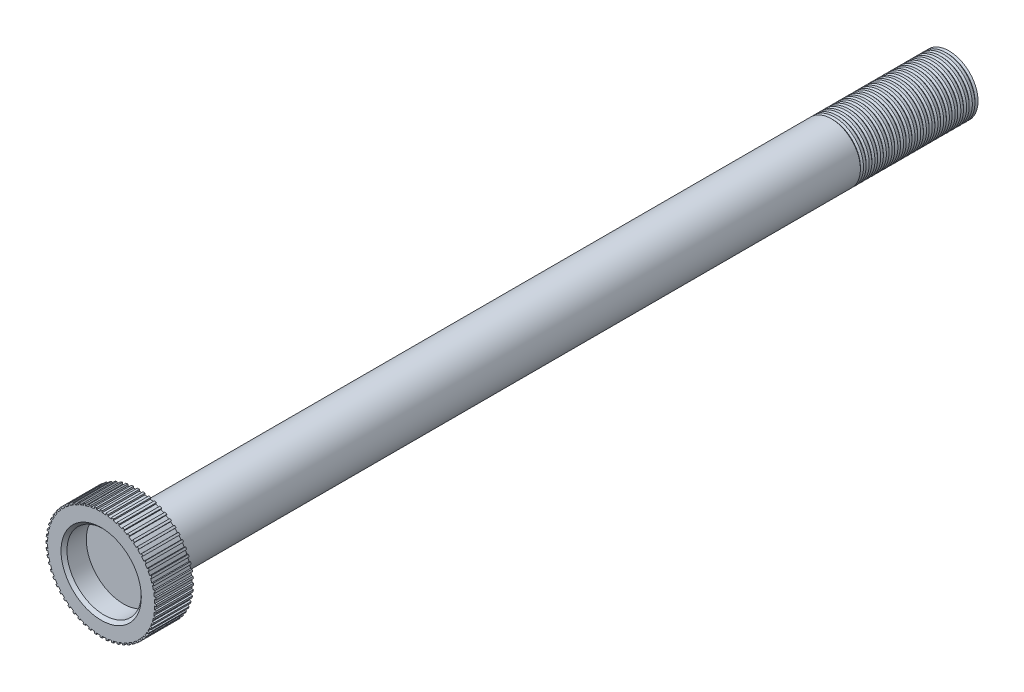
from build123d import *

# Parameters (mm, degrees)
SKETCH1_R          = 9.144
EXTRUDE1_DEPTH     = 6.35
SKETCH2_R          = 6.35
CUT_EXTRUDE1_DEPTH = 3.81
CHAMFER1_SIZE      = 0.508
SKETCH3_R          = 4.953
EXTRUDE2_DEPTH     = 138.43
SKETCH4_W          = 0.35026322
SKETCH4_H          = 0.444823542
EXTRUDE3_DEPTH     = 6.35
CIRPATTERN1_COUNT  = 60
LPATTERN1_COUNT    = 21
LPATTERN1_PITCH    = 0.978000076


with BuildPart() as part:
    # Sketch1 → Extrude1 (new body)
    with BuildSketch(Plane.XY):
        Circle(SKETCH1_R)
    extrude(amount=EXTRUDE1_DEPTH)

    # Sketch2 → Cut-Extrude1 (cut)
    with BuildSketch(Plane.XY.offset(6.35)):
        Circle(SKETCH2_R)
    extrude(amount=-CUT_EXTRUDE1_DEPTH, mode=Mode.SUBTRACT)

    # Chamfer1
    chamfer1_edges = [part.edges().sort_by_distance(p)[0] for p in [
        (-6.35, 0, 6.35),
    ]]
    chamfer(chamfer1_edges, length=CHAMFER1_SIZE)

    # Sketch3 → Extrude2 (add)
    with BuildSketch(Plane(origin=(0, 0, 0), x_dir=(-1, 0, 0), z_dir=(0, 0, -1))):
        Circle(SKETCH3_R)
    extrude(amount=EXTRUDE2_DEPTH)

    # Sketch4 → Extrude3 (add)
    with BuildSketch(Plane.XY):
        with Locations((0, 9.197906763)):
            Rectangle(SKETCH4_W, SKETCH4_H)
    extrude3 = extrude(amount=EXTRUDE3_DEPTH)

    # CirPattern1: Extrude3 ×60 about axis
    cirpattern1_axis = Axis((0, 0, 0), (0, 0, 1))
    for i in range(1, CIRPATTERN1_COUNT):
        add(extrude3.rotate(cirpattern1_axis, i * 360 / CIRPATTERN1_COUNT))

    # Sketch5 → Cut-Revolve1 (revolve, cut)
    with BuildSketch(Plane(origin=(0, 0, 0), x_dir=(1, 0, 0), z_dir=(0, 1, 0))):
        Polygon((-4.953, 138.43), (-4.687658819, 138.164658819), (-4.953, 137.899317638), (-5.218341181, 138.164658819), align=None)
    cut_revolve1 = revolve(axis=Axis((0, 0, -138.43), (0, 0, 1)), mode=Mode.SUBTRACT)

    # LPattern1: Cut-Revolve1 ×21
    with Locations(*[(0, 0, i * LPATTERN1_PITCH) for i in range(1, LPATTERN1_COUNT)]):
        add(cut_revolve1, mode=Mode.SUBTRACT)


solid = part.part
